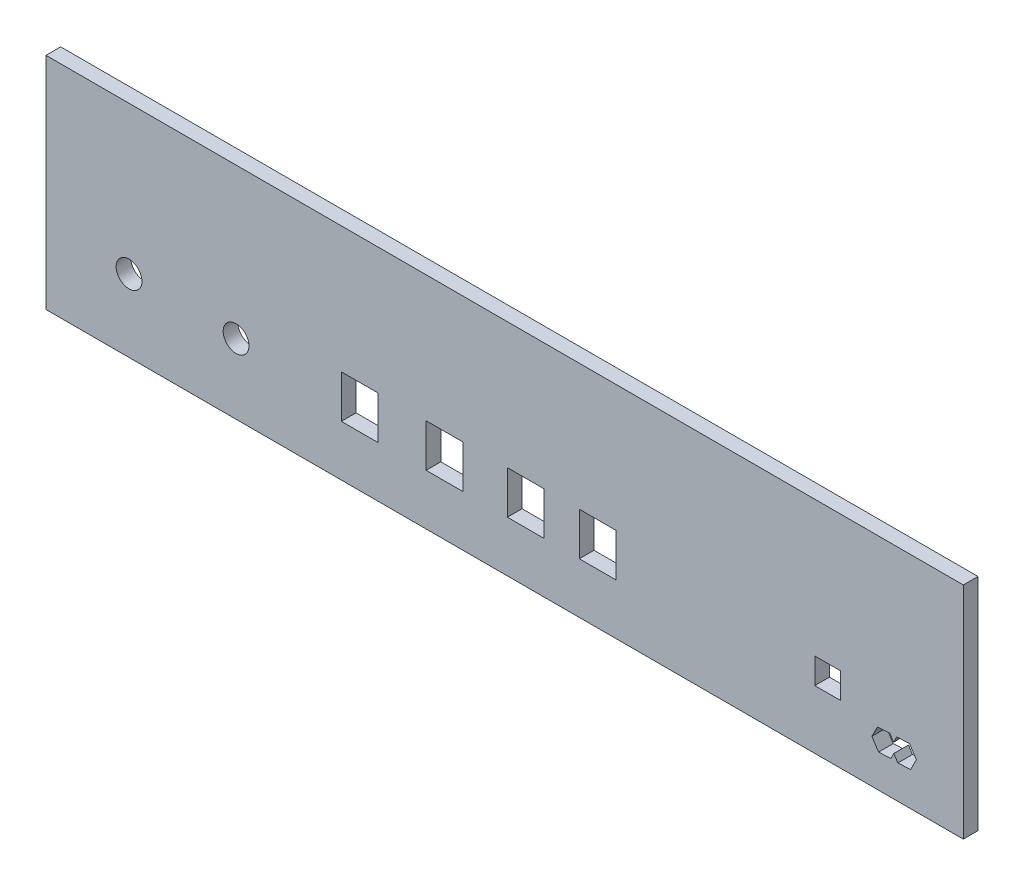
from build123d import *

# Parameters (mm, degrees)
SKETCH1_W           = 250
SKETCH1_H           = 60
BOSS_EXTRUDE1_DEPTH = 4
SKETCH3_R           = 3.51887986
CUT_EXTRUDE1_DEPTH  = 10
SKETCH4_W           = 10
SKETCH4_H           = 11.7
CUT_EXTRUDE2_DEPTH  = 10
SKETCH5_W           = 7
SKETCH5_H           = 7
CUT_EXTRUDE3_DEPTH  = 10
CUT_EXTRUDE4_DEPTH  = 10


with BuildPart() as part:
    # Sketch1 → Boss-Extrude1 (new body)
    with BuildSketch(Plane.XY):
        with Locations((12.569832402, 50.449192367)):
            Rectangle(SKETCH1_W, SKETCH1_H)
    extrude(amount=BOSS_EXTRUDE1_DEPTH)

    # Sketch3 → Cut-Extrude1 (cut)
    with BuildSketch(Plane.XY.offset(4)):
        with Locations((-89.798295426, 40.153008957)):
            Circle(SKETCH3_R)
        with Locations((-117.322145335, -107.100984963)):
            Circle(SKETCH3_R)
        with Locations((-60.625269482, 39.492893663)):
            Circle(SKETCH3_R)
    extrude(amount=-CUT_EXTRUDE1_DEPTH, mode=Mode.SUBTRACT)

    # Sketch4 → Cut-Extrude2 (cut)
    with BuildSketch(Plane.XY.offset(4)):
        with Locations((-3.832712542, 40.15230201)):
            Rectangle(SKETCH4_W, SKETCH4_H)
        with Locations((-26.944599832, 40.15230201)):
            Rectangle(SKETCH4_W, SKETCH4_H)
        with Locations((37.914072819, 40.15230201)):
            Rectangle(SKETCH4_W, SKETCH4_H)
        with Locations((18.306555148, 40.15230201)):
            Rectangle(SKETCH4_W, SKETCH4_H)
    extrude(amount=-CUT_EXTRUDE2_DEPTH, mode=Mode.SUBTRACT)

    # Sketch5 → Cut-Extrude3 (cut)
    with BuildSketch(Plane.XY.offset(4)):
        with Locations((100.58753259, 39.945504984)):
            Rectangle(SKETCH5_W, SKETCH5_H)
    extrude(amount=-CUT_EXTRUDE3_DEPTH, mode=Mode.SUBTRACT)

    # Sketch6 → Cut-Extrude4 (cut)
    with BuildSketch(Plane.XY.offset(4)):
        Polygon((118.560482945, 33.81903225), (117.525576266, 35.420059377), (114.174927615, 35.251571832), (112.645517783, 32.265581209), (114.466756603, 29.44807813), (117.817405254, 29.616565675), (118.634511019, 31.211867406), (117.848178879, 32.428343358), align=None)
        Polygon((119.42955977, 35.515801288), (118.560482945, 33.81903225), (119.346815086, 32.602556298), (118.634511019, 31.211867406), (119.731305434, 29.515098368), (123.19581288, 29.689311308), (124.777193772, 32.776769239), (122.894067216, 35.690014229), align=None)
        Polygon((119.346815086, 32.602556298), (118.560482945, 33.81903225), (117.848178879, 32.428343358), (118.634511019, 31.211867406), align=None)
    extrude(amount=-CUT_EXTRUDE4_DEPTH, mode=Mode.SUBTRACT)


solid = part.part
